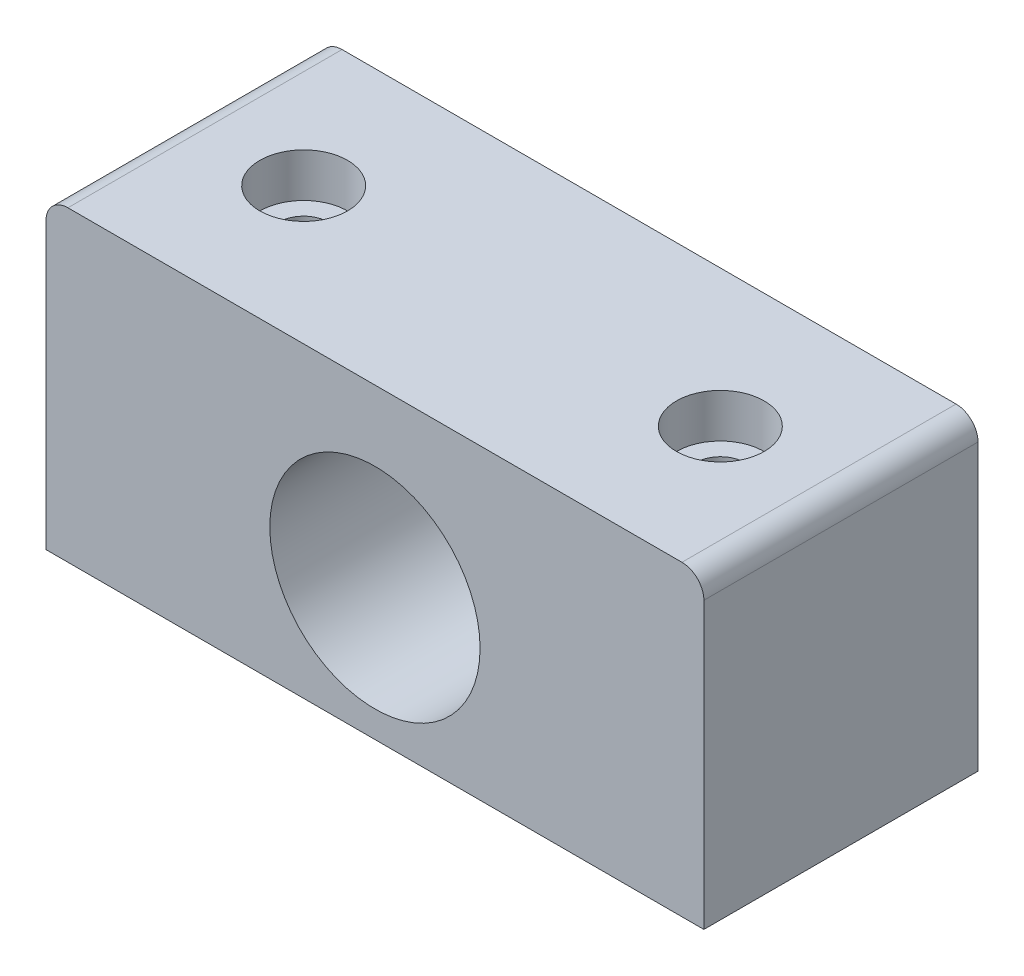
from build123d import *

# Parameters (mm, degrees)
SKETCH1_W                      = 60
SKETCH1_H                      = 25
BOSS_EXTRUDE1_DEPTH            = 28
SKETCH2_R                      = 9.5885
CUT_EXTRUDE1_DEPTH             = 26
CBORE_FOR_M4_SHCS1_D           = 4.5
CBORE_FOR_M4_SHCS1_CBORE_D     = 8
CBORE_FOR_M4_SHCS1_CBORE_DEPTH = 4
FILLET1_R                      = 2


with BuildPart() as part:
    # Sketch1 → Boss-Extrude1 (new body)
    with BuildSketch(Plane(origin=(0, 0, 0), x_dir=(1, 0, 0), z_dir=(0, 1, 0))):
        Rectangle(SKETCH1_W, SKETCH1_H)
    extrude(amount=BOSS_EXTRUDE1_DEPTH)

    # Sketch2 → Cut-Extrude1 (cut, through all)
    with BuildSketch(Plane.XY.offset(12.5)):
        with Locations((0, 12)):
            Circle(SKETCH2_R)
    extrude(amount=-CUT_EXTRUDE1_DEPTH, mode=Mode.SUBTRACT)

    # CBORE for M4 SHCS1 (through all)
    with Locations(Plane(origin=(0, 28, 0), x_dir=(1, 0, 0), z_dir=(0, 1, 0))):
        with Locations((-19, 0), (19, 0)):
            CounterBoreHole(CBORE_FOR_M4_SHCS1_D / 2, CBORE_FOR_M4_SHCS1_CBORE_D / 2, CBORE_FOR_M4_SHCS1_CBORE_DEPTH)

    # Fillet1
    fillet1_edges = [part.edges().sort_by_distance(p)[0] for p in [
        (-30, 28, 0),
        (30, 28, 0),
    ]]
    fillet(fillet1_edges, radius=FILLET1_R)


solid = part.part
